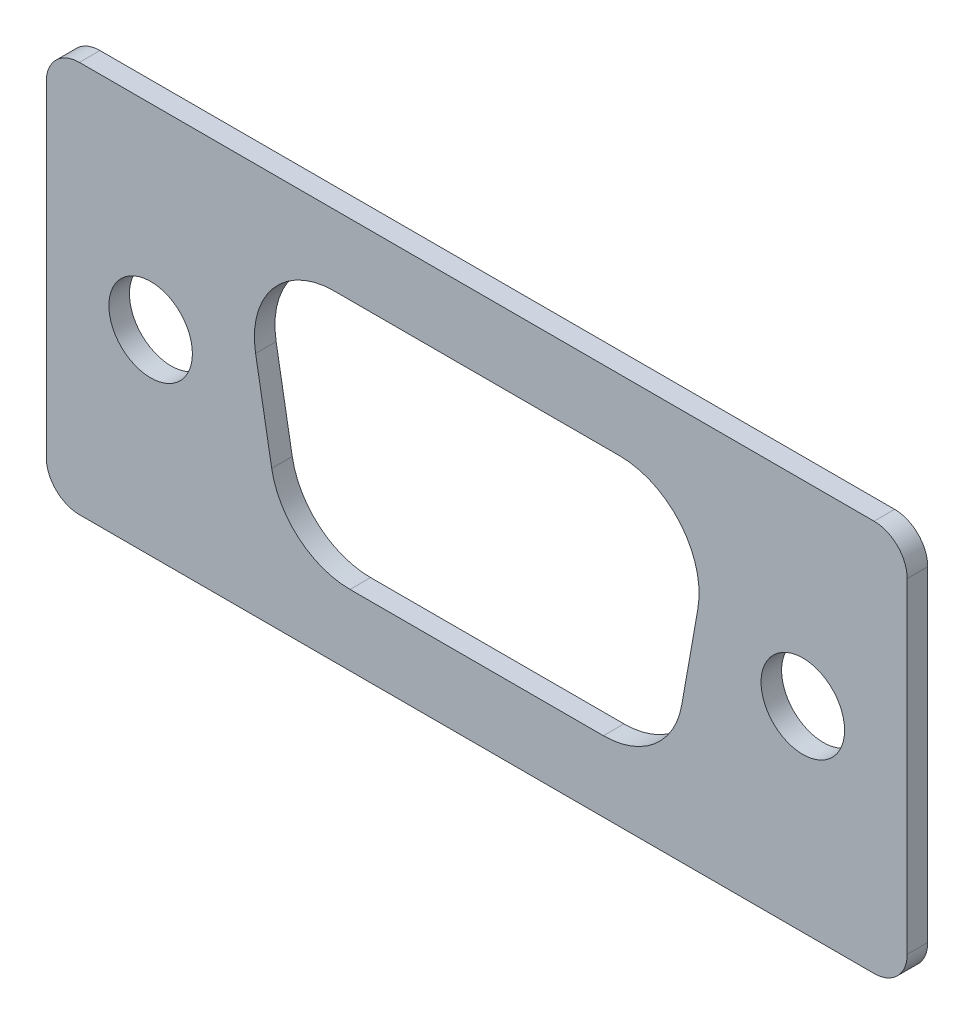
from build123d import *

# Parameters (mm, degrees)
SKETCH1_R           = 1.6002
BOSS_EXTRUDE1_DEPTH = 0.7874


with BuildPart() as part:
    # Sketch1 → Boss-Extrude1 (new body)
    with BuildSketch(Plane.XY):
        with BuildLine():
            Line((1.27, 0), (31.72, 0))
            ThreePointArc((31.72, 0), (32.618025612, 0.371974388), (32.99, 1.27))
            Line((32.99, 1.27), (32.99, 13.74))
            ThreePointArc((32.99, 13.74), (32.618025612, 14.638025612), (31.72, 15.01))
            Line((31.72, 15.01), (1.27, 15.01))
            ThreePointArc((1.27, 15.01), (0.371974388, 14.638025612), (0, 13.74))
            Line((0, 13.74), (0, 1.27))
            ThreePointArc((0, 1.27), (0.371974388, 0.371974388), (1.27, 0))
        make_face()
        with Locations((4, 7.505)):
            Circle(SKETCH1_R, mode=Mode.SUBTRACT)
        with Locations((28.99, 7.505)):
            Circle(SKETCH1_R, mode=Mode.SUBTRACT)
        with BuildLine():
            Line((11.02246495, 12.305), (21.96753505, 12.305))
            ThreePointArc((21.96753505, 12.305), (24.302438512, 11.216216634), (24.969229081, 8.727720354))
            Line((24.969229081, 8.727720354), (24.351379341, 5.223720354))
            ThreePointArc((24.351379341, 5.223720354), (23.308901944, 3.418096537), (21.349685309, 2.705))
            Line((21.349685309, 2.705), (11.640314691, 2.705))
            ThreePointArc((11.640314691, 2.705), (9.681098056, 3.418096537), (8.638620659, 5.223720354))
            Line((8.638620659, 5.223720354), (8.020770919, 8.727720354))
            ThreePointArc((8.020770919, 8.727720354), (8.687561488, 11.216216634), (11.02246495, 12.305))
        make_face(mode=Mode.SUBTRACT)
    extrude(amount=BOSS_EXTRUDE1_DEPTH)


solid = part.part
